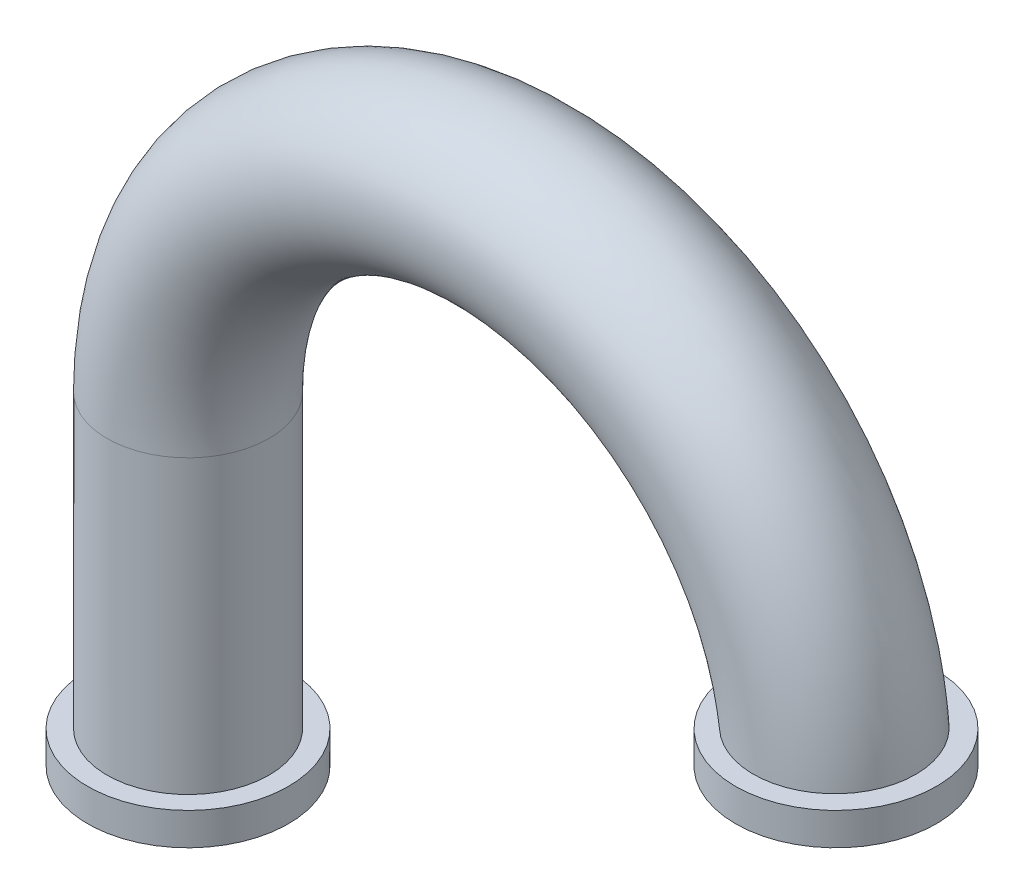
from build123d import *

# Parameters (mm, degrees)
SKETCH3_R    = 0.25
SKETCH3_R_2  = 0.2
SKETCH6_R    = 0.31
SKETCH6_R_2  = 0.21
SKETCH10_R   = 0.31
SKETCH10_R_2 = 0.21


with BuildPart() as part:
    # Sweep-Thin1: sweep along a path in Sketch1
    with BuildLine(Plane.XY) as sweep_thin1_path:
        Line((-2, -1), (-2, 0))
        ThreePointArc((-2, 0), (-1, 1), (0, 0))
    # Sketch3 → Sweep-Thin1 (sweep)
    with BuildSketch(Plane(origin=(0, 0, 0), x_dir=(1, 0, 0), z_dir=(0, 1, 0))):
        Circle(SKETCH3_R)
        Circle(SKETCH3_R_2, mode=Mode.SUBTRACT)
    sweep(path=sweep_thin1_path.line)

    # Sweep-Thin2: sweep along a path in Sketch5
    with BuildLine(Plane.XY) as sweep_thin2_path:
        Line((0, 0), (0, 0.1))
    # Sketch6 → Sweep-Thin2 (sweep)
    with BuildSketch(Plane(origin=(0, 0, 0), x_dir=(1, 0, 0), z_dir=(0, 1, 0))):
        Circle(SKETCH6_R)
        Circle(SKETCH6_R_2, mode=Mode.SUBTRACT)
    sweep(path=sweep_thin2_path.line)

    # Sweep-Thin3: sweep along a path in Sketch9
    with BuildLine(Plane(origin=(-2, 0, 0), x_dir=(0, 0, -1), z_dir=(1, 0, 0))) as sweep_thin3_path:
        Line((0, -1), (0, -0.9))
    # Sketch10 → Sweep-Thin3 (sweep)
    with BuildSketch(Plane(origin=(0, -1, 0), x_dir=(-1, 0, 0), z_dir=(0, -1, 0))):
        with Locations((2, 0)):
            Circle(SKETCH10_R)
        with Locations((2, 0)):
            Circle(SKETCH10_R_2, mode=Mode.SUBTRACT)
    sweep(path=sweep_thin3_path.line)


solid = part.part
